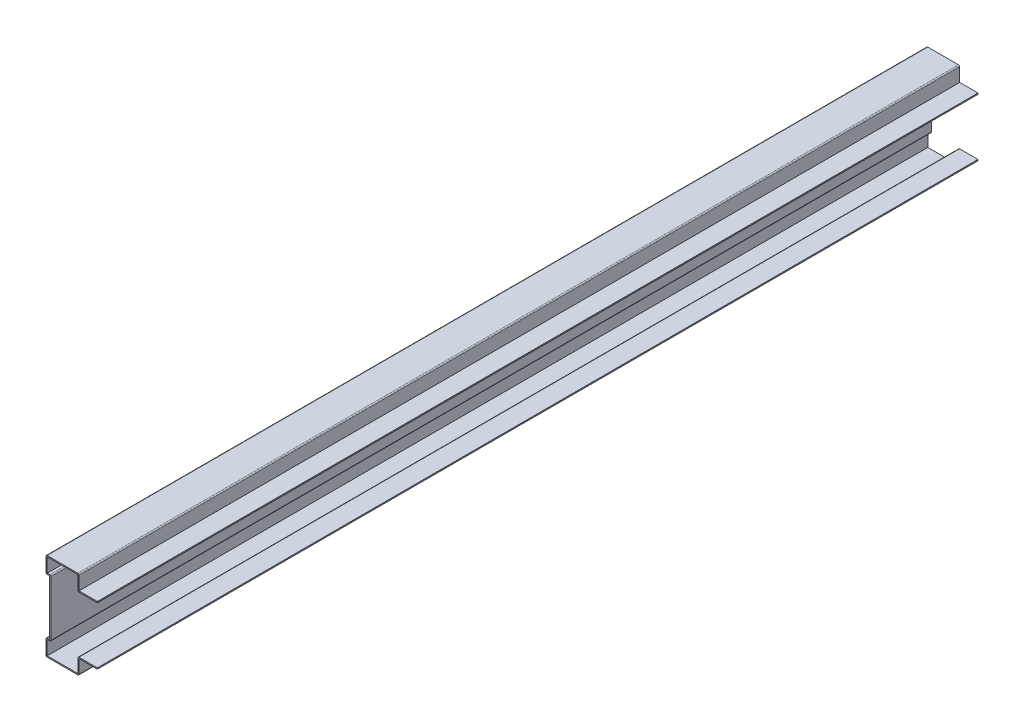
from build123d import *

# Parameters (mm, degrees)
EXTRUDE_THIN1_DEPTH = 762
FILLET1_R           = 1.016


with BuildPart() as part:
    # Sketch1 → Extrude-Thin1 (new body)
    with BuildSketch(Plane.XY):
        Polygon((0, 0), (-15.875, 0), (-15.875, -12.7), (-44.45, -12.7), (-44.45, 1.5875), (-41.275, 1.5875), (-41.275, 49.2125), (-44.45, 49.2125), (-44.45, 63.5), (-15.875, 63.5), (-15.875, 50.8), (0, 50.8), (0, 49.784), (-16.891, 49.784), (-16.891, 62.484), (-43.434, 62.484), (-43.434, 50.2285), (-40.259, 50.2285), (-40.259, 0.5715), (-43.434, 0.5715), (-43.434, -11.684), (-16.891, -11.684), (-16.891, 1.016), (0, 1.016), align=None)
    extrude(amount=-EXTRUDE_THIN1_DEPTH)

    # Fillet1
    fillet1_edges = [part.edges().sort_by_distance(p)[0] for p in [
        (-16.891, 49.784, -381),
        (-40.259, 50.2285, -381),
        (-40.259, 0.5715, -381),
        (-16.891, 1.016, -381),
        (-15.875, -12.7, -381),
        (-44.45, -12.7, -381),
        (-44.45, 1.5875, -381),
        (-44.45, 49.2125, -381),
        (-44.45, 63.5, -381),
        (-15.875, 63.5, -381),
    ]]
    fillet(fillet1_edges, radius=FILLET1_R)


solid = part.part
